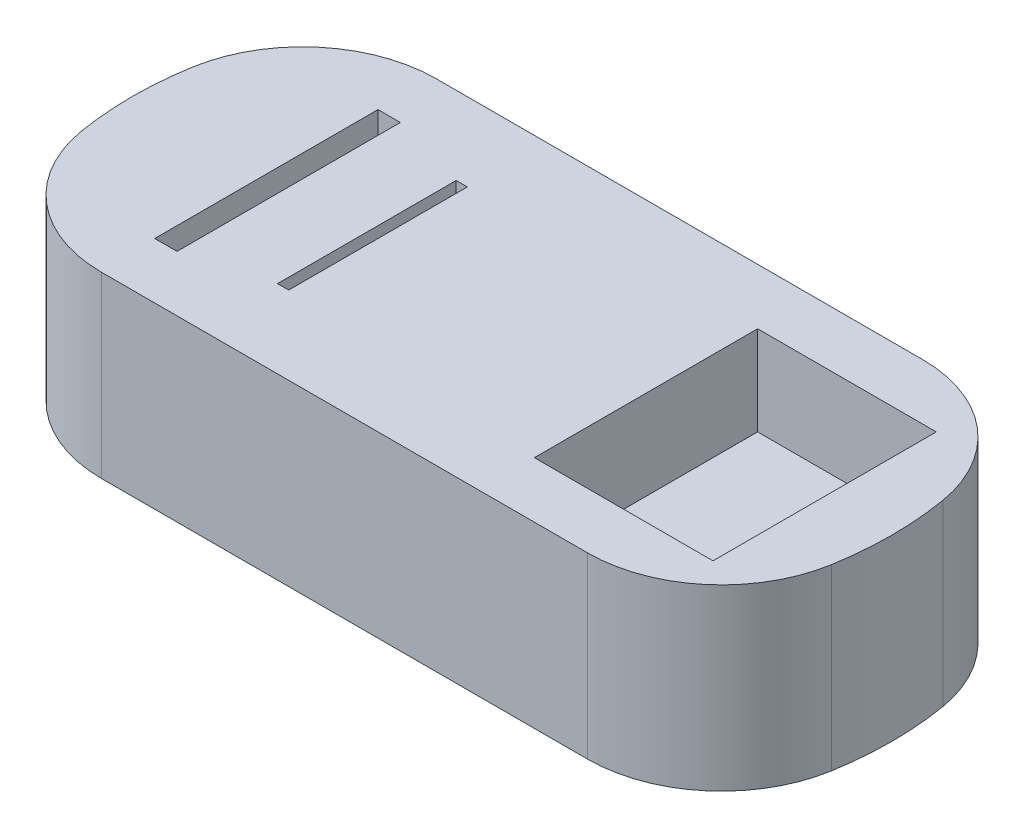
from build123d import *

# Parameters (mm, degrees)
SALIENTE_EXTRUIR1_DEPTH = 80
REDONDEO1_R             = 60
CROQUIS2_W              = 10
CROQUIS2_H              = 100
CORTAR_EXTRUIR1_DEPTH   = 20
CROQUIS3_W              = 5
CROQUIS3_H              = 80
CORTAR_EXTRUIR2_DEPTH   = 40
CROQUIS4_W              = 80
CROQUIS4_H              = 100
CORTAR_EXTRUIR3_DEPTH   = 40


with BuildPart() as part:
    # Croquis1 → Saliente-Extruir1 (new body)
    with BuildSketch(Plane(origin=(0, 0, 0), x_dir=(1, 0, 0), z_dir=(0, 1, 0))):
        with BuildLine():
            Line((-150, -75), (150, -75))
            ThreePointArc((150, -75), (170.096189432, 0), (150, 75))
            Line((150, 75), (-150, 75))
            ThreePointArc((-150, 75), (-170.096189432, 0), (-150, -75))
        make_face()
    extrude(amount=SALIENTE_EXTRUIR1_DEPTH)

    # Redondeo1
    redondeo1_edges = [part.edges().sort_by_distance(p)[0] for p in [
        (150, 40, 75),
        (-150, 40, 75),
        (-150, 40, -75),
        (150, 40, -75),
    ]]
    fillet(redondeo1_edges, radius=REDONDEO1_R)

    # Croquis2 → Cortar-Extruir1 (cut)
    with BuildSketch(Plane(origin=(0, 80, 0), x_dir=(1, 0, 0), z_dir=(0, 1, 0))):
        with Locations((-105, 0)):
            Rectangle(CROQUIS2_W, CROQUIS2_H)
    extrude(amount=-CORTAR_EXTRUIR1_DEPTH, mode=Mode.SUBTRACT)

    # Croquis3 → Cortar-Extruir2 (cut)
    with BuildSketch(Plane(origin=(0, 80, 0), x_dir=(1, 0, 0), z_dir=(0, 1, 0))):
        with Locations((-62.5, 0)):
            Rectangle(CROQUIS3_W, CROQUIS3_H)
    extrude(amount=-CORTAR_EXTRUIR2_DEPTH, mode=Mode.SUBTRACT)

    # Croquis4 → Cortar-Extruir3 (cut)
    with BuildSketch(Plane(origin=(0, 80, 0), x_dir=(1, 0, 0), z_dir=(0, 1, 0))):
        with Locations((100, 0)):
            Rectangle(CROQUIS4_W, CROQUIS4_H)
    extrude(amount=-CORTAR_EXTRUIR3_DEPTH, mode=Mode.SUBTRACT)


solid = part.part
